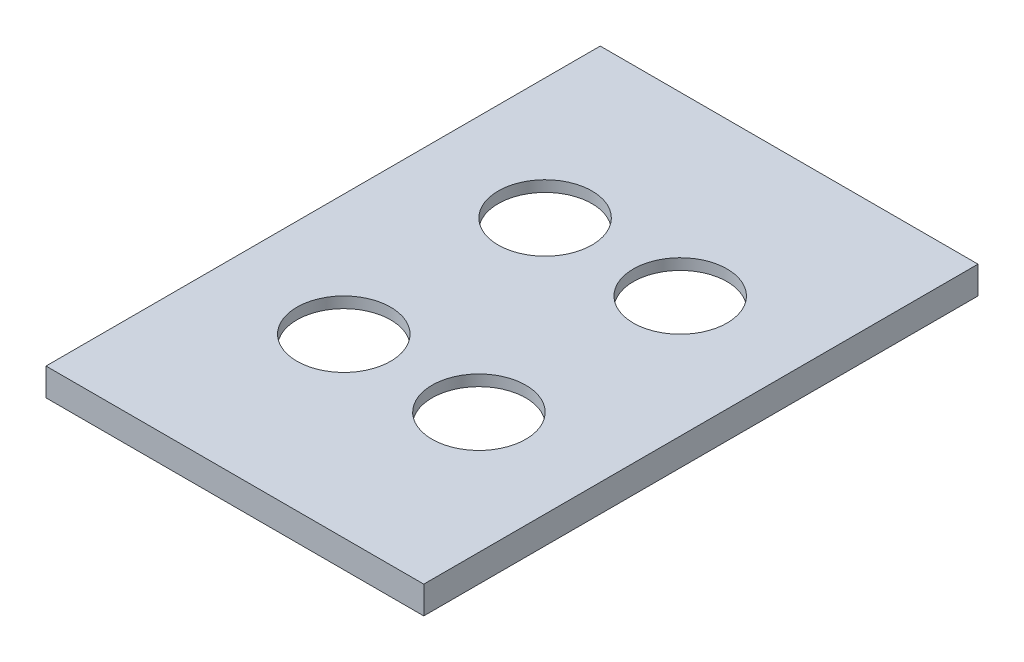
from build123d import *

# Parameters (mm, degrees)
CROQUIS1_W                   = 64.5
CROQUIS1_H                   = 96.5
CROQUIS1_R                   = 8.5
SALIENTE_EXTRUIR4_DEPTH      = 2
CROQUIS2_W                   = 68.5
CROQUIS2_H                   = 100.5
CROQUIS2_W_2                 = 64.5
CROQUIS2_H_2                 = 96.5
SALIENTE_EXTRUIR5_DEPTH      = 3
SALIENTE_EXTRUIR5_DEPTH_BACK = 2


with BuildPart() as part:
    # Croquis1 → Saliente-Extruir4 (new body)
    with BuildSketch(Plane(origin=(0, 0, 0), x_dir=(1, 0, 0), z_dir=(0, 1, 0))):
        with Locations((7.75, -11.25)):
            Rectangle(CROQUIS1_W, CROQUIS1_H)
        with Locations((20, -29.5)):
            Circle(CROQUIS1_R, mode=Mode.SUBTRACT)
        with Locations((-4.5, -29.5)):
            Circle(CROQUIS1_R, mode=Mode.SUBTRACT)
        with Locations((-4.5, 7)):
            Circle(CROQUIS1_R, mode=Mode.SUBTRACT)
        with Locations((20, 7)):
            Circle(CROQUIS1_R, mode=Mode.SUBTRACT)
    extrude(amount=SALIENTE_EXTRUIR4_DEPTH)

    # Croquis2 → Saliente-Extruir5 (add, two sides)
    with BuildSketch(Plane.XZ) as saliente_extruir5_sk:
        with Locations((7.75, 11.25)):
            Rectangle(CROQUIS2_W, CROQUIS2_H)
        with Locations((7.75, 11.25)):
            Rectangle(CROQUIS2_W_2, CROQUIS2_H_2, mode=Mode.SUBTRACT)
    extrude(amount=SALIENTE_EXTRUIR5_DEPTH)
    extrude(saliente_extruir5_sk.sketch, amount=-SALIENTE_EXTRUIR5_DEPTH_BACK)


solid = part.part
